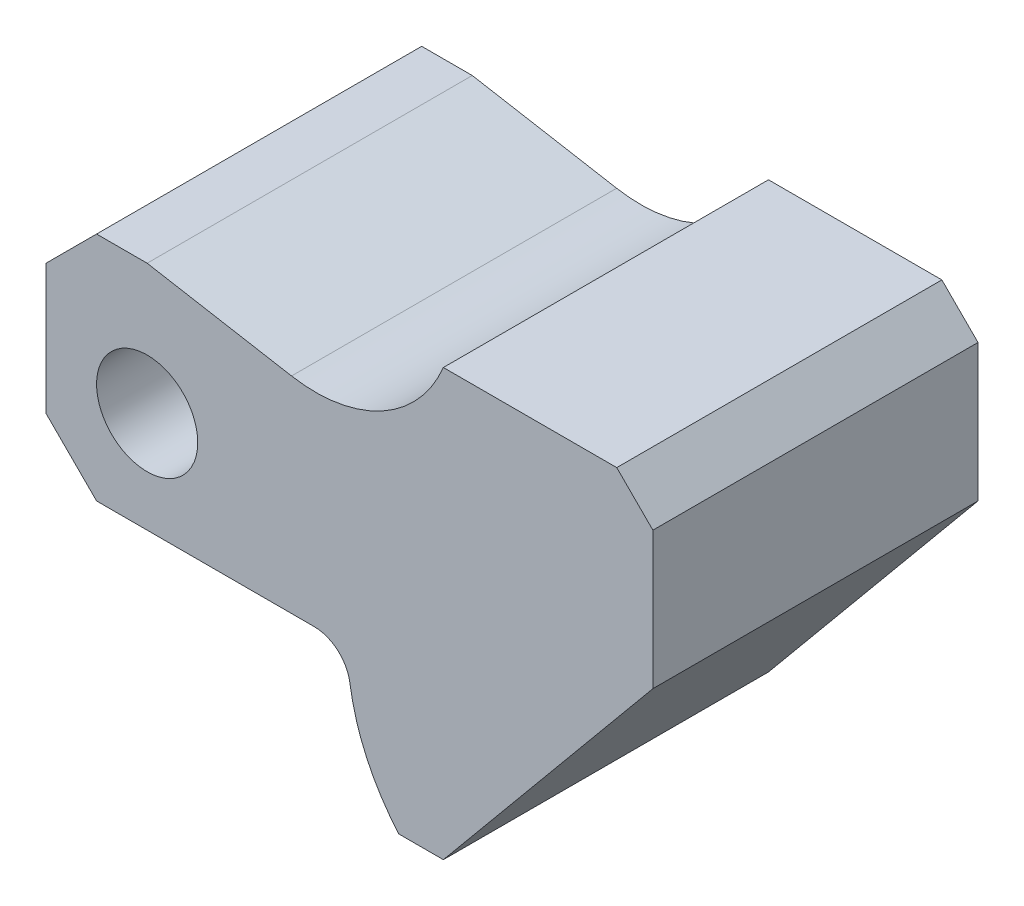
from build123d import *

# Parameters (mm, degrees)
ESQUISSE2_R        = 7
BOSS_EXTRU_2_DEPTH = 22.5


with BuildPart() as part:
    # Esquisse2 → Boss.-Extru.2 (new body, symmetric)
    with BuildSketch(Plane.XY):
        with BuildLine():
            Line((48.833954843, -19), (55, -19))
            Line((55, -19), (84, 16))
            Line((84, 16), (84, 35))
            Line((84, 35), (79, 40))
            Line((79, 40), (55, 40))
            ThreePointArc((55, 40), (46.518108988, 30.544085173), (33.984940886, 28.476115714))
            Line((33.984940886, 28.476115714), (14, 32))
            Line((14, 32), (7, 32))
            Line((7, 32), (0, 25))
            Line((0, 25), (0, 7))
            Line((0, 7), (7, 0))
            Line((7, 0), (37.112513701, 0))
            ThreePointArc((37.112513701, 0), (40.377749482, -1.213413768), (42.058152443, -4.264705882))
            ThreePointArc((42.058152443, -4.264705882), (44.394982646, -12.115672061), (48.833954843, -19))
        make_face()
        with Locations((14, 14)):
            Circle(ESQUISSE2_R, mode=Mode.SUBTRACT)
    extrude(amount=BOSS_EXTRU_2_DEPTH, both=True)


solid = part.part
